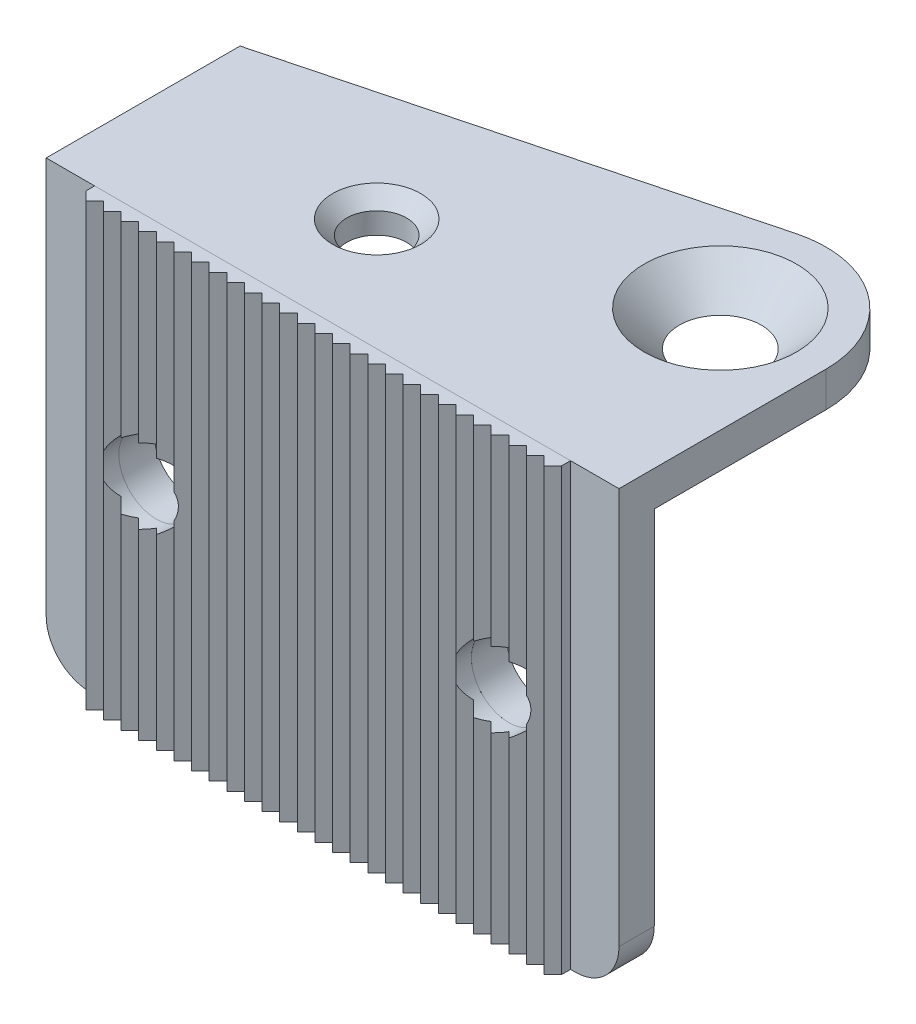
from build123d import *

# Parameters (mm, degrees)
BOSS_EXTRU_1_DEPTH                             = 4
BOSS_EXTRU_2_DEPTH                             = 4
ESQUISSE3_R                                    = 4.25
ENL_V_MAT_EXTRU_1_DEPTH                        = 4
FRAISAGE_POUR_VIS_T_TE_FRAIS_E_M81_D           = 9
FRAISAGE_POUR_VIS_T_TE_FRAIS_E_M81_CSINK_D     = 17.3
FRAISAGE_POUR_VIS_T_TE_FRAIS_E_M81_CSINK_ANGLE = 90
TROU_TARAUD_M81_D                              = 6.8
TROU_TARAUD_M81_CSINK_D                        = 10
TROU_TARAUD_M81_CSINK_ANGLE                    = 90
BOSS_EXTRU_3_DEPTH                             = 50
ESQUISSE9_R                                    = 4.25
ENL_V_MAT_EXTRU_2_DEPTH                        = 3


with BuildPart() as part:
    # Esquisse1 → Boss.-Extru.1 (new body)
    with BuildSketch(Plane.XY):
        with BuildLine():
            Line((-32.5, 25), (32.5, 25))
            Line((32.5, 25), (32.5, -20))
            ThreePointArc((32.5, -20), (31.035533906, -23.535533906), (27.5, -25))
            Line((27.5, -25), (-27.5, -25))
            ThreePointArc((-27.5, -25), (-31.035533906, -23.535533906), (-32.5, -20))
            Line((-32.5, -20), (-32.5, 25))
        make_face()
    extrude(amount=BOSS_EXTRU_1_DEPTH)

    # Esquisse2 → Boss.-Extru.2 (add)
    with BuildSketch(Plane(origin=(0, 25, 0), x_dir=(1, 0, 0), z_dir=(0, 1, 0))):
        with BuildLine():
            Line((-32.5, 0), (-32.5, 18))
            Line((-32.5, 18), (17.454515727, 31.10711099))
            ThreePointArc((17.454515727, 31.10711099), (27.829876831, 29.001205484), (32.5, 19.5))
            Line((32.5, 19.5), (32.5, 0))
            Line((32.5, 0), (-32.5, 0))
        make_face()
    extrude(amount=-BOSS_EXTRU_2_DEPTH)

    # Esquisse3 → Enlèv. mat.-Extru.1 (cut)
    with BuildSketch(Plane.XY.offset(4)):
        with Locations((20, 0)):
            Circle(ESQUISSE3_R)
        with Locations((-20, 0)):
            Circle(ESQUISSE3_R)
    extrude(amount=-ENL_V_MAT_EXTRU_1_DEPTH, mode=Mode.SUBTRACT)

    # Fraisage pour vis à tête fraisée M81 (through all)
    with Locations(Plane(origin=(0, 25, 0), x_dir=(1, 0, 0), z_dir=(0, 1, 0))):
        with Locations((20.5, 19.5)):
            CounterSinkHole(FRAISAGE_POUR_VIS_T_TE_FRAIS_E_M81_D / 2, FRAISAGE_POUR_VIS_T_TE_FRAIS_E_M81_CSINK_D / 2, counter_sink_angle=FRAISAGE_POUR_VIS_T_TE_FRAIS_E_M81_CSINK_ANGLE)

    # Trou taraudé M81 (through all)
    with Locations(Plane(origin=(0, 25, 0), x_dir=(1, 0, 0), z_dir=(0, 1, 0))):
        with Locations((-7.75, 8.753707136)):
            CounterSinkHole(TROU_TARAUD_M81_D / 2, TROU_TARAUD_M81_CSINK_D / 2, counter_sink_angle=TROU_TARAUD_M81_CSINK_ANGLE)


with BuildPart() as body_2:
    # Esquisse8 → Boss.-Extru.3 (new body)
    with BuildSketch(Plane.XZ.offset(25)):
        Polygon((27, 4), (27, 5), (26, 6), (25, 5), (24, 6), (23, 5), (22, 6), (21, 5), (20, 6), (19, 5), (18, 6), (17, 5), (16, 6), (15, 5), (14, 6), (13, 5), (12, 6), (11, 5), (10, 6), (9, 5), (8, 6), (7, 5), (6, 6), (5, 5), (4, 6), (3, 5), (2, 6), (1, 5), (0, 6), (-1, 5), (-2, 6), (-3, 5), (-4, 6), (-5, 5), (-6, 6), (-7, 5), (-8, 6), (-9, 5), (-10, 6), (-11, 5), (-12, 6), (-13, 5), (-14, 6), (-15, 5), (-16, 6), (-17, 5), (-18, 6), (-19, 5), (-20, 6), (-21, 5), (-22, 6), (-23, 5), (-24, 6), (-25, 5), (-26, 6), (-27, 5), (-27, 4), align=None)
    extrude(amount=-BOSS_EXTRU_3_DEPTH)

    # Esquisse9 → Enlèv. mat.-Extru.2 (cut, through all)
    with BuildSketch(Plane(origin=(0, 0, 4), x_dir=(-1, 0, 0), z_dir=(0, 0, -1))):
        with Locations((-20, 0)):
            Circle(ESQUISSE9_R)
        with Locations((20, 0)):
            Circle(ESQUISSE9_R)
    extrude(amount=-ENL_V_MAT_EXTRU_2_DEPTH, mode=Mode.SUBTRACT)


solid = Compound([part.part, body_2.part])
